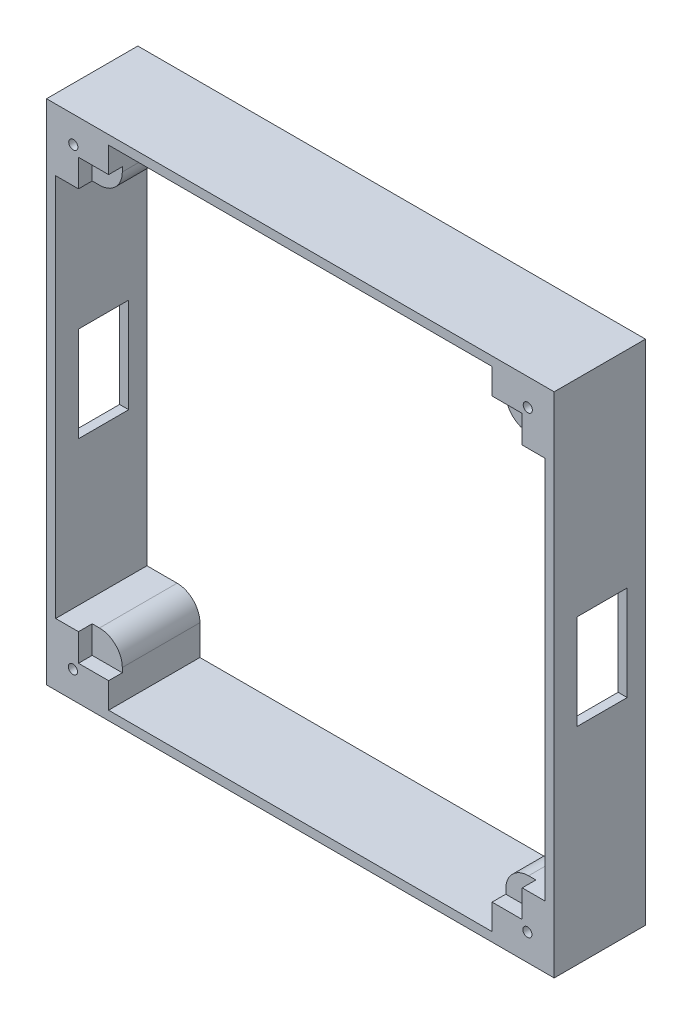
from build123d import *

# Parameters (mm, degrees)
SKICA1_W                 = 55.6
SKICA1_H                 = 55.6
SKICA1_W_2               = 53.6
SKICA1_H_2               = 53.6
P_IDAT_VYSUNUT_M1_DEPTH  = 10
SKICA3_W                 = 5.8
SKICA3_H                 = 5.8
P_IDAT_VYSUNUT_M2_DEPTH  = 10
ZAOBLIT1_R               = 2.5
SKICA4_R                 = 2.4
ODEBRAT_VYSUNUT_M1_DEPTH = 8
SKICA5_R                 = 0.5
ODEBRAT_VYSUNUT_M2_DEPTH = 2
SKICA6_W                 = 48.6
SKICA6_H                 = 48
ODEBRAT_VYSUNUT_M3_DEPTH = 1.5
SKICA7_W                 = 5.5
SKICA7_H                 = 10.4
ODEBRAT_VYSUNUT_M4_DEPTH = 55.6


with BuildPart() as part:
    # Skica1 → Přidat vysunutím1 (new body)
    with BuildSketch(Plane.XY):
        Rectangle(SKICA1_W, SKICA1_H)
        Rectangle(SKICA1_W_2, SKICA1_H_2, mode=Mode.SUBTRACT)
    extrude(amount=P_IDAT_VYSUNUT_M1_DEPTH)

    # Skica3 → Přidat vysunutím2 (add)
    with BuildSketch(Plane(origin=(0, 0, 0), x_dir=(-1, 0, 0), z_dir=(0, 0, -1))):
        with Locations((23.9, -23.9)):
            Rectangle(SKICA3_W, SKICA3_H)
        with Locations((23.9, 23.9)):
            Rectangle(SKICA3_W, SKICA3_H)
        with Locations((-23.9, -23.9)):
            Rectangle(SKICA3_W, SKICA3_H)
        with Locations((-23.9, 23.9)):
            Rectangle(SKICA3_W, SKICA3_H)
    extrude(amount=-P_IDAT_VYSUNUT_M2_DEPTH)

    # Zaoblit1
    zaoblit1_edges = [part.edges().sort_by_distance(p)[0] for p in [
        (-21, 21, 5),
        (-21, -21, 5),
        (21, -21, 5),
        (21, 21, 5),
    ]]
    fillet(zaoblit1_edges, radius=ZAOBLIT1_R)

    # Skica4 → Odebrat vysunutím1 (cut)
    with BuildSketch(Plane(origin=(0, 0, 0), x_dir=(-1, 0, 0), z_dir=(0, 0, -1))):
        with Locations((23.9, 23.9)):
            Circle(SKICA4_R)
        with Locations((23.9, -23.9)):
            Circle(SKICA4_R)
        with Locations((-23.9, -23.9)):
            Circle(SKICA4_R)
        with Locations((-23.9, 23.9)):
            Circle(SKICA4_R)
    extrude(amount=-ODEBRAT_VYSUNUT_M1_DEPTH, mode=Mode.SUBTRACT)

    # Skica5 → Odebrat vysunutím2 (cut)
    with BuildSketch(Plane(origin=(0, 0, 8), x_dir=(-1, 0, 0), z_dir=(0, 0, -1))):
        with Locations((24.868963017, 24.910500208)):
            Circle(SKICA5_R)
        with Locations((-24.910500208, 24.868963017)):
            Circle(SKICA5_R)
        with Locations((24.910500208, -24.868963017)):
            Circle(SKICA5_R)
        with Locations((-24.868963017, -24.910500208)):
            Circle(SKICA5_R)
    extrude(amount=-ODEBRAT_VYSUNUT_M2_DEPTH, mode=Mode.SUBTRACT)

    # Skica6 → Odebrat vysunutím3 (cut)
    with BuildSketch(Plane.XY.offset(10)):
        Rectangle(SKICA6_W, SKICA6_H)
    extrude(amount=-ODEBRAT_VYSUNUT_M3_DEPTH, mode=Mode.SUBTRACT)

    # Skica7 → Odebrat vysunutím4 (cut)
    with BuildSketch(Plane(origin=(27.8, 0, 0), x_dir=(0, 0, -1), z_dir=(1, 0, 0))):
        with Locations((-4.75, 0)):
            Rectangle(SKICA7_W, SKICA7_H)
    extrude(amount=-ODEBRAT_VYSUNUT_M4_DEPTH, mode=Mode.SUBTRACT)


solid = part.part
